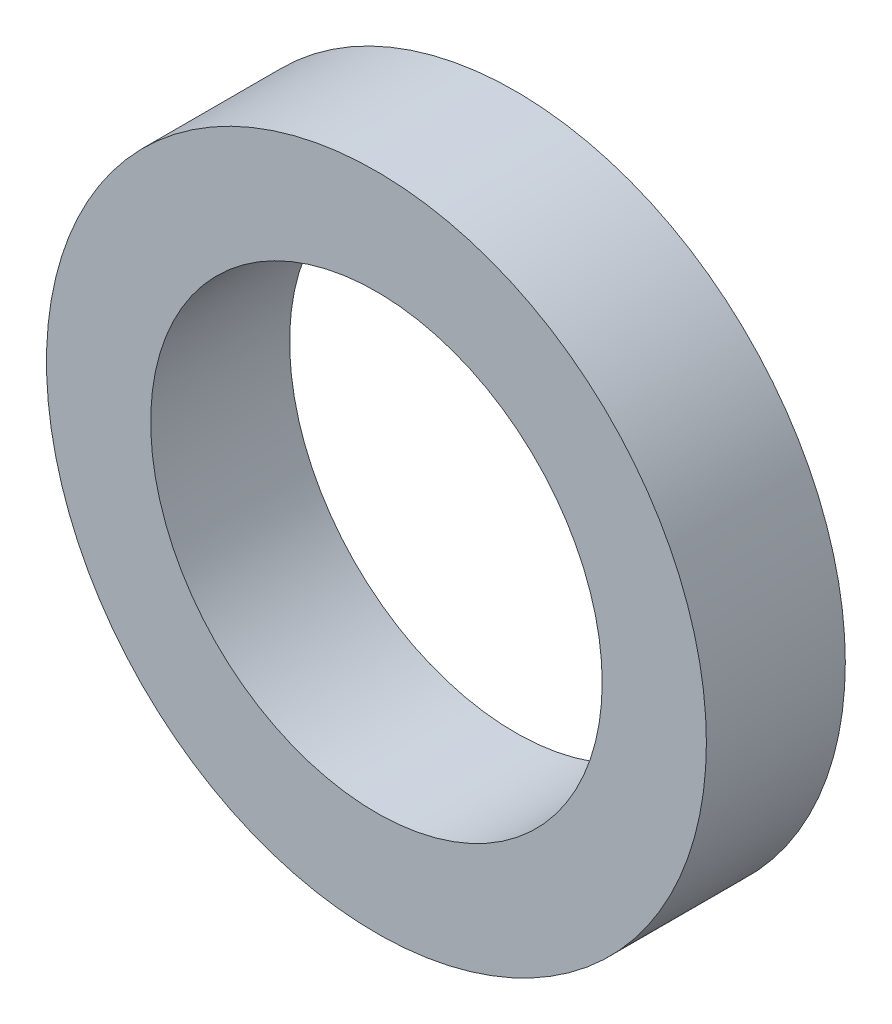
from build123d import *

# Parameters (mm, degrees)
SKETCH1_R           = 9.5
SKETCH1_R_2         = 6.5
BOSS_EXTRUDE1_DEPTH = 4


with BuildPart() as part:
    # Sketch1 → Boss-Extrude1 (new body)
    with BuildSketch(Plane.XY):
        Circle(SKETCH1_R)
        Circle(SKETCH1_R_2, mode=Mode.SUBTRACT)
    extrude(amount=BOSS_EXTRUDE1_DEPTH)


solid = part.part
